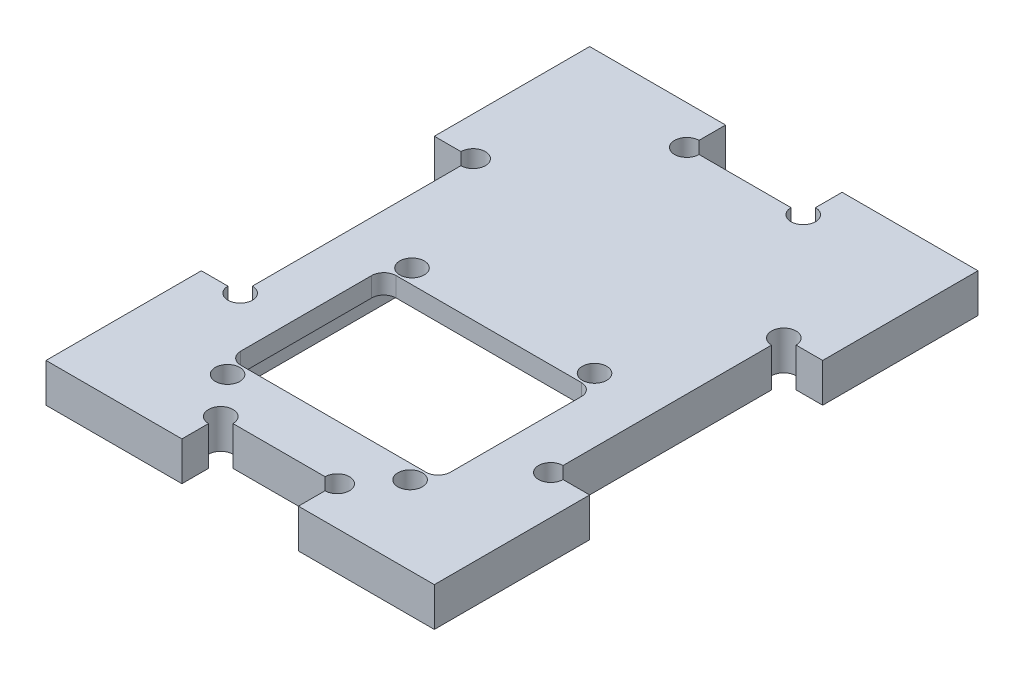
from build123d import *

# Parameters (mm, degrees)
SKETCH1_W               = 50
SKETCH1_H               = 70
BOSS_EXTRUDE1_DEPTH     = 5
CUT_EXTRUDE1_DEPTH      = 2.5
SKETCH3_R               = 1.57480315
CUT_EXTRUDE5_DEPTH      = 6
CUT_EXTRUDE2_DEPTH      = 2.5
SKETCH5_W               = 5
SKETCH5_H               = 30
SKETCH5_W_2             = 15
SKETCH5_H_2             = 5
CUT_EXTRUDE3_DEPTH      = 1
CUT_EXTRUDE3_DEPTH_BACK = 6
SKETCH6_R               = 1.57480315
CUT_EXTRUDE4_DEPTH      = 6


with BuildPart() as part:
    # Sketch1 → Boss-Extrude1 (new body)
    with BuildSketch(Plane(origin=(0, 0, 0), x_dir=(1, 0, 0), z_dir=(0, 1, 0))):
        with Locations((25, 35)):
            Rectangle(SKETCH1_W, SKETCH1_H)
        with BuildLine():
            Line((13.07480315, 12), (36.92519685, 12))
            ThreePointArc((36.92519685, 12), (38.038750837, 12.461249163), (38.5, 13.57480315))
            Line((38.5, 13.57480315), (38.5, 30.42519685))
            ThreePointArc((38.5, 30.42519685), (38.038750837, 31.538750837), (36.92519685, 32))
            Line((36.92519685, 32), (13.07480315, 32))
            ThreePointArc((13.07480315, 32), (11.961249163, 31.538750837), (11.5, 30.42519685))
            Line((11.5, 30.42519685), (11.5, 13.57480315))
            ThreePointArc((11.5, 13.57480315), (11.961249163, 12.461249163), (13.07480315, 12))
        make_face(mode=Mode.SUBTRACT)
    extrude(amount=BOSS_EXTRUDE1_DEPTH)

    # Sketch2 → Cut-Extrude1 (cut)
    with BuildSketch(Plane.XZ):
        with BuildLine():
            Line((12.07480315, -37), (37.92519685, -37))
            ThreePointArc((37.92519685, -37), (39.038750837, -36.538750837), (39.5, -35.42519685))
            Line((39.5, -35.42519685), (39.5, -8.57480315))
            ThreePointArc((39.5, -8.57480315), (39.038750837, -7.461249163), (37.92519685, -7))
            Line((37.92519685, -7), (12.07480315, -7))
            ThreePointArc((12.07480315, -7), (10.961249163, -7.461249163), (10.5, -8.57480315))
            Line((10.5, -8.57480315), (10.5, -35.42519685))
            ThreePointArc((10.5, -35.42519685), (10.961249163, -36.538750837), (12.07480315, -37))
        make_face()
    extrude(amount=-CUT_EXTRUDE1_DEPTH, mode=Mode.SUBTRACT)

    # Sketch3 → Cut-Extrude5 (cut, through all)
    with BuildSketch(Plane(origin=(0, 5, 0), x_dir=(1, 0, 0), z_dir=(0, 1, 0))):
        with Locations((13.25, 33.875)):
            Circle(SKETCH3_R)
        with Locations((36.75, 33.875)):
            Circle(SKETCH3_R)
        with Locations((36.75, 10.125)):
            Circle(SKETCH3_R)
        with Locations((13.25, 10.125)):
            Circle(SKETCH3_R)
    extrude(amount=-CUT_EXTRUDE5_DEPTH, mode=Mode.SUBTRACT)

    # Sketch4 → Cut-Extrude2 (cut)
    with BuildSketch(Plane.XZ):
        with BuildLine():
            Line((34.17519685, -61), (15.82480315, -61))
            ThreePointArc((15.82480315, -61), (14.711249163, -60.538750837), (14.25, -59.42519685))
            Line((14.25, -59.42519685), (14.25, -43.07480315))
            ThreePointArc((14.25, -43.07480315), (14.711249163, -41.961249163), (15.82480315, -41.5))
            Line((15.82480315, -41.5), (34.17519685, -41.5))
            ThreePointArc((34.17519685, -41.5), (35.288750837, -41.961249163), (35.75, -43.07480315))
            Line((35.75, -43.07480315), (35.75, -59.42519685))
            ThreePointArc((35.75, -59.42519685), (35.288750837, -60.538750837), (34.17519685, -61))
        make_face()
    extrude(amount=-CUT_EXTRUDE2_DEPTH, mode=Mode.SUBTRACT)

    # Sketch5 → Cut-Extrude3 (cut, two sides)
    with BuildSketch(Plane(origin=(0, 5, 0), x_dir=(1, 0, 0), z_dir=(0, 1, 0))) as cut_extrude3_sk:
        with Locations((2.5, 35)):
            Rectangle(SKETCH5_W, SKETCH5_H)
        with Locations((25, 67.5)):
            Rectangle(SKETCH5_W_2, SKETCH5_H_2)
        with Locations((47.5, 35)):
            Rectangle(SKETCH5_W, SKETCH5_H)
        with Locations((25, 2.5)):
            Rectangle(SKETCH5_W_2, SKETCH5_H_2)
    extrude(amount=CUT_EXTRUDE3_DEPTH, mode=Mode.SUBTRACT)
    extrude(cut_extrude3_sk.sketch, amount=-CUT_EXTRUDE3_DEPTH_BACK, mode=Mode.SUBTRACT)

    # Sketch6 → Cut-Extrude4 (cut, through all)
    with BuildSketch(Plane.XZ):
        with Locations((5, -50)):
            Circle(SKETCH6_R)
        with Locations((5, -20)):
            Circle(SKETCH6_R)
        with Locations((17.5, -5)):
            Circle(SKETCH6_R)
        with Locations((32.5, -5)):
            Circle(SKETCH6_R)
        with Locations((45, -20)):
            Circle(SKETCH6_R)
        with Locations((45, -50)):
            Circle(SKETCH6_R)
        with Locations((32.5, -65)):
            Circle(SKETCH6_R)
        with Locations((17.5, -65)):
            Circle(SKETCH6_R)
    extrude(amount=-CUT_EXTRUDE4_DEPTH, mode=Mode.SUBTRACT)


solid = part.part
